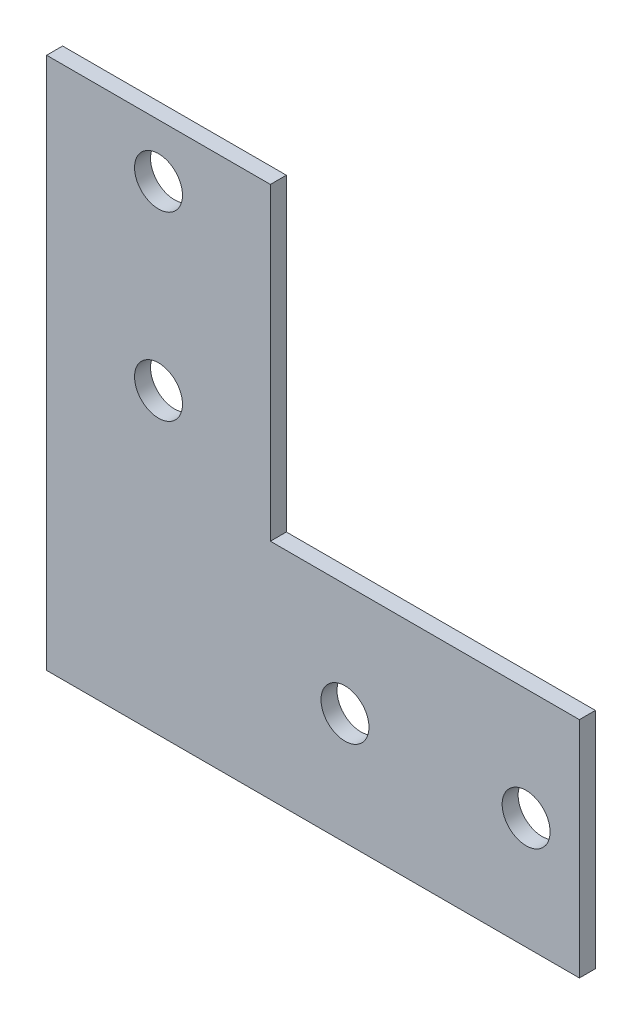
from build123d import *

# Parameters (mm, degrees)
SKETCH_1_R      = 4.5
EXTRUDE_1_DEPTH = 3


with BuildPart() as part:
    # Эскиз1 → Бобышка-Вытянуть1 (new body)
    with BuildSketch(Plane.XY):
        Polygon((0, 100), (0, 0), (100, 0), (100, 42), (42, 42), (42, 100), align=None)
        with Locations((21, 90)):
            Circle(SKETCH_1_R, mode=Mode.SUBTRACT)
        with Locations((21, 56)):
            Circle(SKETCH_1_R, mode=Mode.SUBTRACT)
        with Locations((56, 21)):
            Circle(SKETCH_1_R, mode=Mode.SUBTRACT)
        with Locations((90, 21)):
            Circle(SKETCH_1_R, mode=Mode.SUBTRACT)
    extrude(amount=EXTRUDE_1_DEPTH)


solid = part.part
